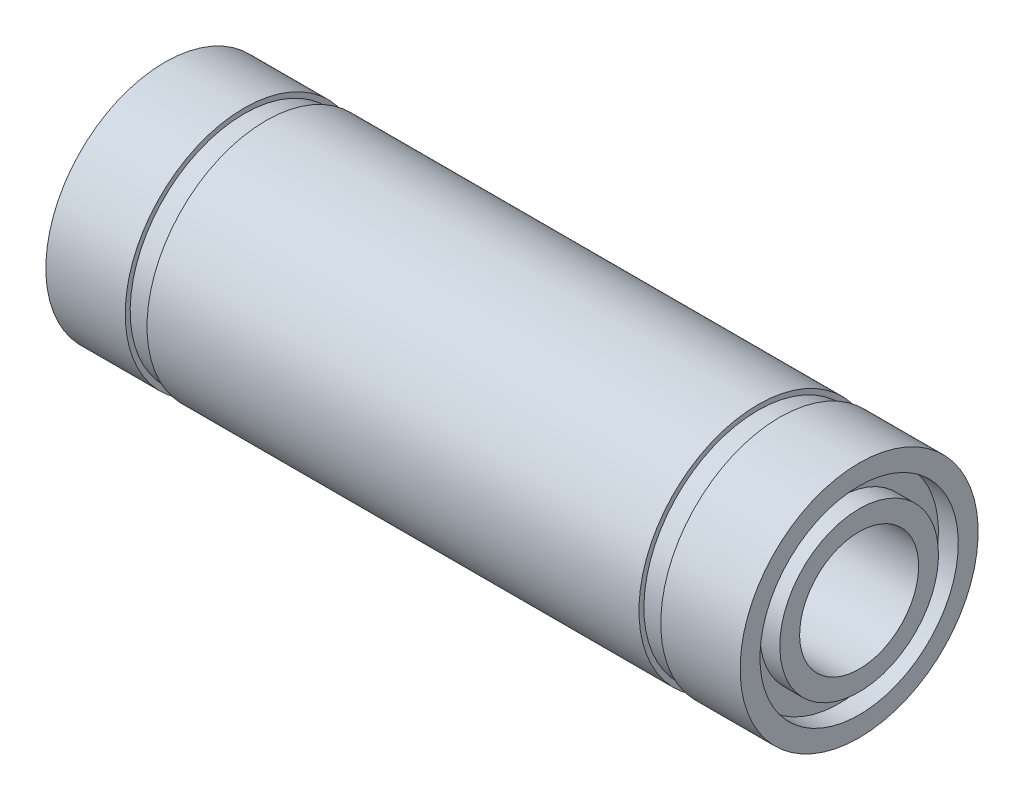
from build123d import *


with BuildPart() as part:
    # Esboço1 → Revolução1 (revolve)
    with BuildSketch(Plane.XY):
        Polygon((-17.5, 6), (-13.5, 6), (-13.5, 5.75), (-12.4, 5.75), (-12.4, 6), (12.4, 6), (12.4, 5.75), (13.5, 5.75), (13.5, 6), (17.5, 6), (17.5, 5), (16.5, 5), (16.5, 4), (17.5, 4), (17.5, 3), (-17.5, 3), (-17.5, 4), (-16.5, 4), (-16.5, 5), (-17.5, 5), align=None)
    revolve(axis=Axis((0, 0, 0), (-1, 0, 0)))


solid = part.part
